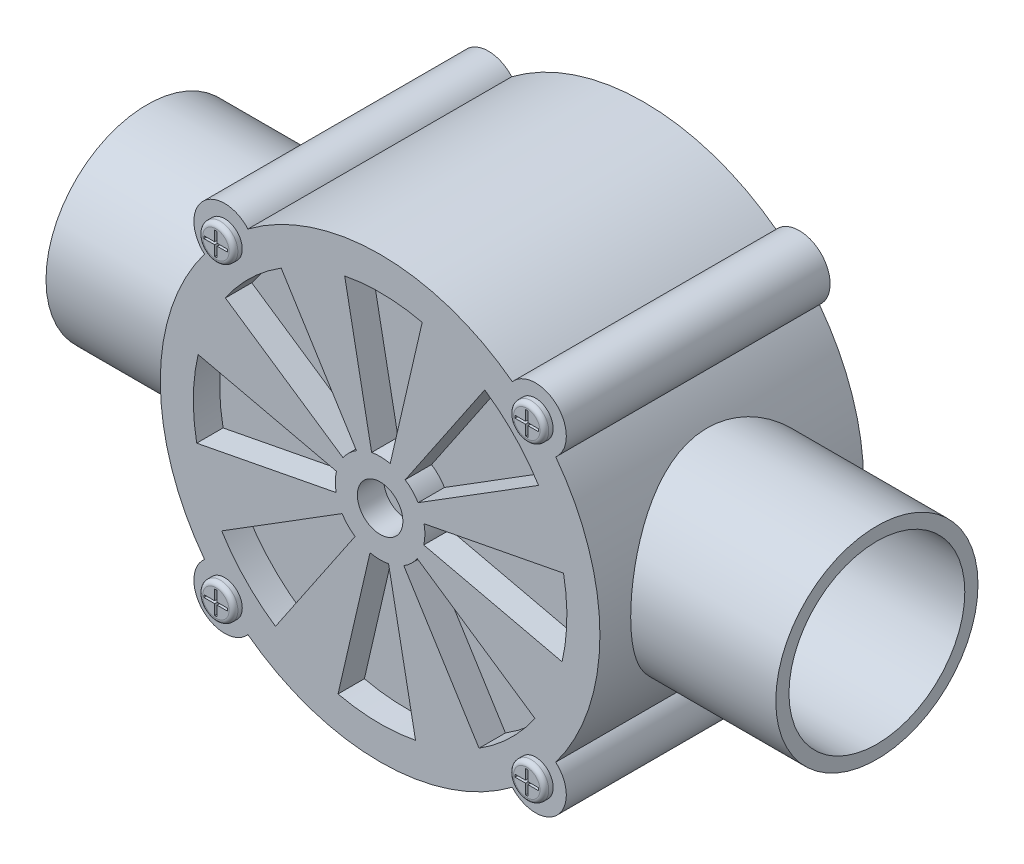
from build123d import *

# Parameters (mm, degrees)
CROQUIS1_R              = 25
SALIENTE_EXTRUIR1_DEPTH = 15
CROQUIS2_R              = 3.5
SALIENTE_EXTRUIR2_DEPTH = 30
CROQUIS3_R              = 2.587437636
CORTAR_EXTRUIR2_DEPTH   = 3
CROQUIS5_R              = 11.5
CROQUIS5_R_2            = 10
SALIENTE_EXTRUIR3_DEPTH = 41.5
CROQUIS6_R              = 2
SALIENTE_EXTRUIR4_DEPTH = 1
REDONDEO1_R             = 0.5


with BuildPart() as part:
    # Croquis1 → Saliente-Extruir1 (new body, symmetric)
    with BuildSketch(Plane.XY):
        Circle(CROQUIS1_R)
    extrude(amount=SALIENTE_EXTRUIR1_DEPTH, both=True)

    # Croquis2 → Saliente-Extruir2 (add)
    with BuildSketch(Plane.XY.offset(15)):
        with Locations((17.67766953, 17.67766953)):
            Circle(CROQUIS2_R)
        with Locations((17.67766953, -17.67766953)):
            Circle(CROQUIS2_R)
        with Locations((-17.67766953, -17.67766953)):
            Circle(CROQUIS2_R)
        with Locations((-17.67766953, 17.67766953)):
            Circle(CROQUIS2_R)
    extrude(amount=-SALIENTE_EXTRUIR2_DEPTH)

    # Croquis3 → Cortar-Extruir2 (cut)
    with BuildSketch(Plane.XY.offset(15)):
        with BuildLine():
            ThreePointArc((4.319545019, 2.696732525), (3.665933656, 3.534369239), (2.852733766, 4.218144799))
            Line((2.852733766, 4.218144799), (11.901403829, 17.597802243))
            ThreePointArc((11.901403829, 17.597802243), (15.294016347, 14.74513889), (18.0208368, 11.250577671))
            Line((18.0208368, 11.250577671), (4.319545019, 2.696732525))
        make_face()
        with BuildLine():
            ThreePointArc((4.96125743, -1.147501719), (5.091383003, -0.093030091), (4.999866182, 0.965491401))
            Line((4.999866182, 0.965491401), (20.859088653, 4.027961947))
            ThreePointArc((20.859088653, 4.027961947), (21.240890369, -0.388114972), (20.698015667, -4.787296141))
            Line((20.698015667, -4.787296141), (4.96125743, -1.147501719))
        make_face()
        with BuildLine():
            ThreePointArc((2.696732525, -4.319545019), (3.534369239, -3.665933656), (4.218144799, -2.852733766))
            Line((4.218144799, -2.852733766), (17.597802243, -11.901403829))
            ThreePointArc((17.597802243, -11.901403829), (14.74513889, -15.294016347), (11.250577671, -18.0208368))
            Line((11.250577671, -18.0208368), (2.696732525, -4.319545019))
        make_face()
        with BuildLine():
            ThreePointArc((-1.147501719, -4.96125743), (-0.093030091, -5.091383003), (0.965491401, -4.999866182))
            Line((0.965491401, -4.999866182), (4.027961947, -20.859088653))
            ThreePointArc((4.027961947, -20.859088653), (-0.388114972, -21.240890369), (-4.787296141, -20.698015667))
            Line((-4.787296141, -20.698015667), (-1.147501719, -4.96125743))
        make_face()
        with BuildLine():
            ThreePointArc((-4.319545019, -2.696732525), (-3.665933656, -3.534369239), (-2.852733766, -4.218144799))
            Line((-2.852733766, -4.218144799), (-11.901403829, -17.597802243))
            ThreePointArc((-11.901403829, -17.597802243), (-15.294016347, -14.74513889), (-18.0208368, -11.250577671))
            Line((-18.0208368, -11.250577671), (-4.319545019, -2.696732525))
        make_face()
        with BuildLine():
            ThreePointArc((-4.96125743, 1.147501719), (-5.091383003, 0.093030091), (-4.999866182, -0.965491401))
            Line((-4.999866182, -0.965491401), (-20.859088653, -4.027961947))
            ThreePointArc((-20.859088653, -4.027961947), (-21.240890369, 0.388114972), (-20.698015667, 4.787296141))
            Line((-20.698015667, 4.787296141), (-4.96125743, 1.147501719))
        make_face()
        with BuildLine():
            ThreePointArc((-2.696732525, 4.319545019), (-3.534369239, 3.665933656), (-4.218144799, 2.852733766))
            Line((-4.218144799, 2.852733766), (-17.597802243, 11.901403829))
            ThreePointArc((-17.597802243, 11.901403829), (-14.74513889, 15.294016347), (-11.250577671, 18.0208368))
            Line((-11.250577671, 18.0208368), (-2.696732525, 4.319545019))
        make_face()
        with BuildLine():
            Line((1.147501719, 4.96125743), (4.787296141, 20.698015667))
            ThreePointArc((4.787296141, 20.698015667), (0.388114972, 21.240890369), (-4.027961947, 20.859088653))
            Line((-4.027961947, 20.859088653), (-0.965491401, 4.999866182))
            ThreePointArc((-0.965491401, 4.999866182), (0.093030091, 5.091383003), (1.147501719, 4.96125743))
        make_face()
        Circle(CROQUIS3_R)
    cortar_extruir2 = extrude(amount=-CORTAR_EXTRUIR2_DEPTH, mode=Mode.SUBTRACT)

    # Simetría1: Cortar-Extruir2 across plane
    add(cortar_extruir2.mirror(Plane.XY), mode=Mode.SUBTRACT)

    # Croquis5 → Saliente-Extruir3 (add, symmetric)
    with BuildSketch(Plane(origin=(0, 0, 0), x_dir=(0, 0, -1), z_dir=(1, 0, 0))):
        Circle(CROQUIS5_R)
        Circle(CROQUIS5_R_2, mode=Mode.SUBTRACT)
    extrude(amount=SALIENTE_EXTRUIR3_DEPTH, both=True)

    # Croquis6 → Saliente-Extruir4 (add)
    with BuildSketch(Plane.XY.offset(15)):
        with Locations((17.67766953, 17.67766953)):
            Circle(CROQUIS6_R)
        Polygon((17.536932067, 17.82231847), (17.536932067, 18.981472271), (17.818406992, 18.981472271), (17.818406992, 17.82231847), (19.017708505, 17.82231847), (19.017708505, 17.533020589), (17.818406992, 17.533020589), (17.818406992, 16.373866788), (17.536932067, 16.373866788), (17.536932067, 17.533020589), (16.337630554, 17.533020589), (16.337630554, 17.82231847), align=None, mode=Mode.SUBTRACT)
        with Locations((17.67766953, -17.67766953)):
            Circle(CROQUIS6_R)
        Polygon((17.818406992, -16.373866788), (17.818406992, -17.533020589), (19.017708505, -17.533020589), (19.017708505, -17.82231847), (17.818406992, -17.82231847), (17.818406992, -18.981472271), (17.536932067, -18.981472271), (17.536932067, -17.82231847), (16.337630554, -17.82231847), (16.337630554, -17.533020589), (17.536932067, -17.533020589), (17.536932067, -16.373866788), align=None, mode=Mode.SUBTRACT)
        with Locations((-17.67766953, -17.67766953)):
            Circle(CROQUIS6_R)
        Polygon((-17.818406992, -16.373866788), (-17.536932067, -16.373866788), (-17.536932067, -17.533020589), (-16.337630554, -17.533020589), (-16.337630554, -17.82231847), (-17.536932067, -17.82231847), (-17.536932067, -18.981472271), (-17.818406992, -18.981472271), (-17.818406992, -17.82231847), (-19.017708505, -17.82231847), (-19.017708505, -17.533020589), (-17.818406992, -17.533020589), align=None, mode=Mode.SUBTRACT)
        with Locations((-17.67766953, 17.67766953)):
            Circle(CROQUIS6_R)
        Polygon((-17.818406992, 16.373866788), (-17.818406992, 17.533020589), (-19.017708505, 17.533020589), (-19.017708505, 17.82231847), (-17.818406992, 17.82231847), (-17.818406992, 18.981472271), (-17.536932067, 18.981472271), (-17.536932067, 17.82231847), (-16.337630554, 17.82231847), (-16.337630554, 17.533020589), (-17.536932067, 17.533020589), (-17.536932067, 16.373866788), align=None, mode=Mode.SUBTRACT)
    extrude(amount=SALIENTE_EXTRUIR4_DEPTH)

    # Redondeo1
    redondeo1_edges = [part.edges().sort_by_distance(p)[0] for p in [
        (15.67766953, 17.67766953, 16),
        (15.67766953, -17.67766953, 16),
        (-19.67766953, -17.67766953, 16),
        (-19.67766953, 17.67766953, 16),
    ]]
    fillet(redondeo1_edges, radius=REDONDEO1_R)


solid = part.part
